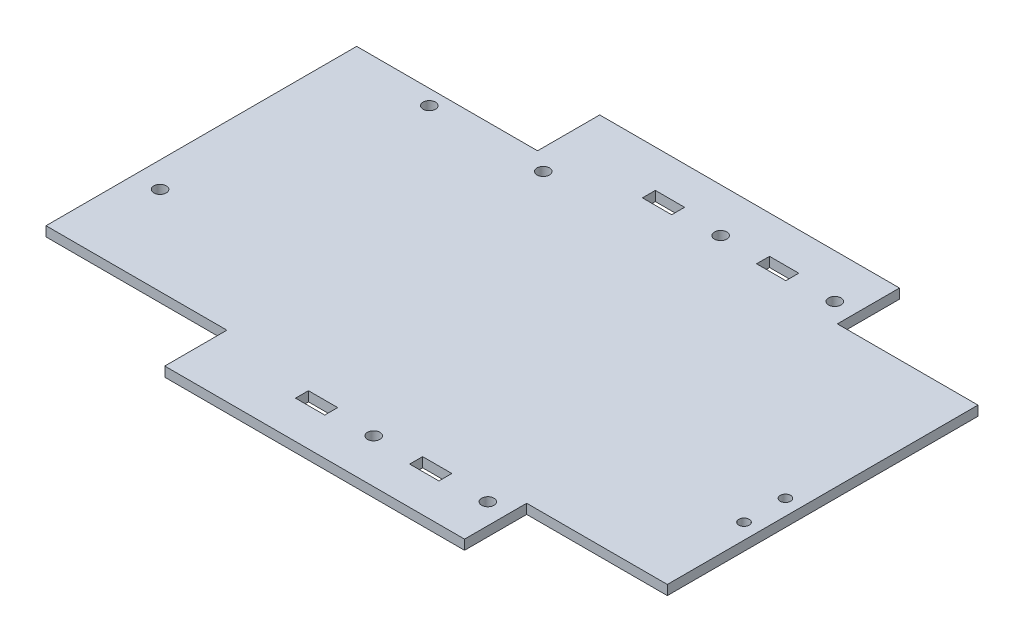
from build123d import *

# Parameters (mm, degrees)
SKETCH1_W                  = 152.4
SKETCH1_H                  = 2.38125
BOSS_EXTRUDE1_DEPTH        = 76.2
F_31_0_12_DIAMETER_HOLE4_D = 3.048
SKETCH25_W                 = 73.533
SKETCH25_H                 = 8.89
BOSS_EXTRUDE2_DEPTH        = 2.38125
SKETCH26_W                 = 7.1755
SKETCH26_H                 = 3.175
CUT_EXTRUDE3_DEPTH         = 3.38125
F_31_0_12_DIAMETER_HOLE6_D = 3.048
SKETCH32_W                 = 73.533
SKETCH32_H                 = 6.35
BOSS_EXTRUDE3_DEPTH        = 2.38125
SKETCH31_R                 = 1.27
CUT_EXTRUDE4_DEPTH         = 3.38125


with BuildPart() as part:
    # Sketch1 → Boss-Extrude1 (new body)
    with BuildSketch(Plane.XY):
        with Locations((76.2, 1.190625)):
            Rectangle(SKETCH1_W, SKETCH1_H)
    extrude(amount=BOSS_EXTRUDE1_DEPTH)

    # #31 (0.12) Diameter Hole4 (through all)
    with Locations(Plane(origin=(0, 2.38125, 0), x_dir=(1, 0, 0), z_dir=(0, 1, 0))):
        with Locations((49.448559218, -3.690103872), (21.508561504, -3.690103872), (6.268559218, -54.490103872)):
            Hole(F_31_0_12_DIAMETER_HOLE4_D / 2)

    # Sketch25 → Boss-Extrude2 (add)
    with BuildSketch(Plane(origin=(0, 2.38125, 0), x_dir=(1, 0, 0), z_dir=(0, 1, 0))):
        with Locations((81.135059218, 4.445)):
            Rectangle(SKETCH25_W, SKETCH25_H)
        with Locations((81.135059218, -80.645)):
            Rectangle(SKETCH25_W, SKETCH25_H)
    extrude(amount=-BOSS_EXTRUDE2_DEPTH)

    # Sketch26 → Cut-Extrude3 (cut, through all)
    with BuildSketch(Plane(origin=(0, 2.38125, 0), x_dir=(1, 0, 0), z_dir=(0, 1, 0))):
        with Locations((70.816309218, 4.445)):
            Rectangle(SKETCH26_W, SKETCH26_H)
        with Locations((98.819809218, 4.445)):
            Rectangle(SKETCH26_W, SKETCH26_H)
        with Locations((98.819809218, -80.645)):
            Rectangle(SKETCH26_W, SKETCH26_H)
        with Locations((70.816309218, -80.645)):
            Rectangle(SKETCH26_W, SKETCH26_H)
    extrude(amount=-CUT_EXTRUDE3_DEPTH, mode=Mode.SUBTRACT)

    # #31 (0.12) Diameter Hole6 (through all)
    with Locations(Plane(origin=(0, 2.38125, 0), x_dir=(1, 0, 0), z_dir=(0, 1, 0))):
        with Locations((84.818059218, 4.445), (112.821559218, 4.445), (112.821559218, -80.645), (84.818059218, -80.645)):
            Hole(F_31_0_12_DIAMETER_HOLE6_D / 2)

    # Sketch32 → Boss-Extrude3 (add)
    with BuildSketch(Plane.XZ):
        with Locations((81.135059218, 88.265)):
            Rectangle(SKETCH32_W, SKETCH32_H)
        with Locations((81.135059218, -12.065)):
            Rectangle(SKETCH32_W, SKETCH32_H)
    extrude(amount=-BOSS_EXTRUDE3_DEPTH)

    # Sketch31 → Cut-Extrude4 (cut, through all)
    with BuildSketch(Plane(origin=(0, 0, 0), x_dir=(-1, 0, 0), z_dir=(0, -1, 0))):
        with Locations((-148.59, -43.421592432)):
            Circle(SKETCH31_R)
        with Locations((-148.59, -53.581592432)):
            Circle(SKETCH31_R)
    extrude(amount=-CUT_EXTRUDE4_DEPTH, mode=Mode.SUBTRACT)


solid = part.part
